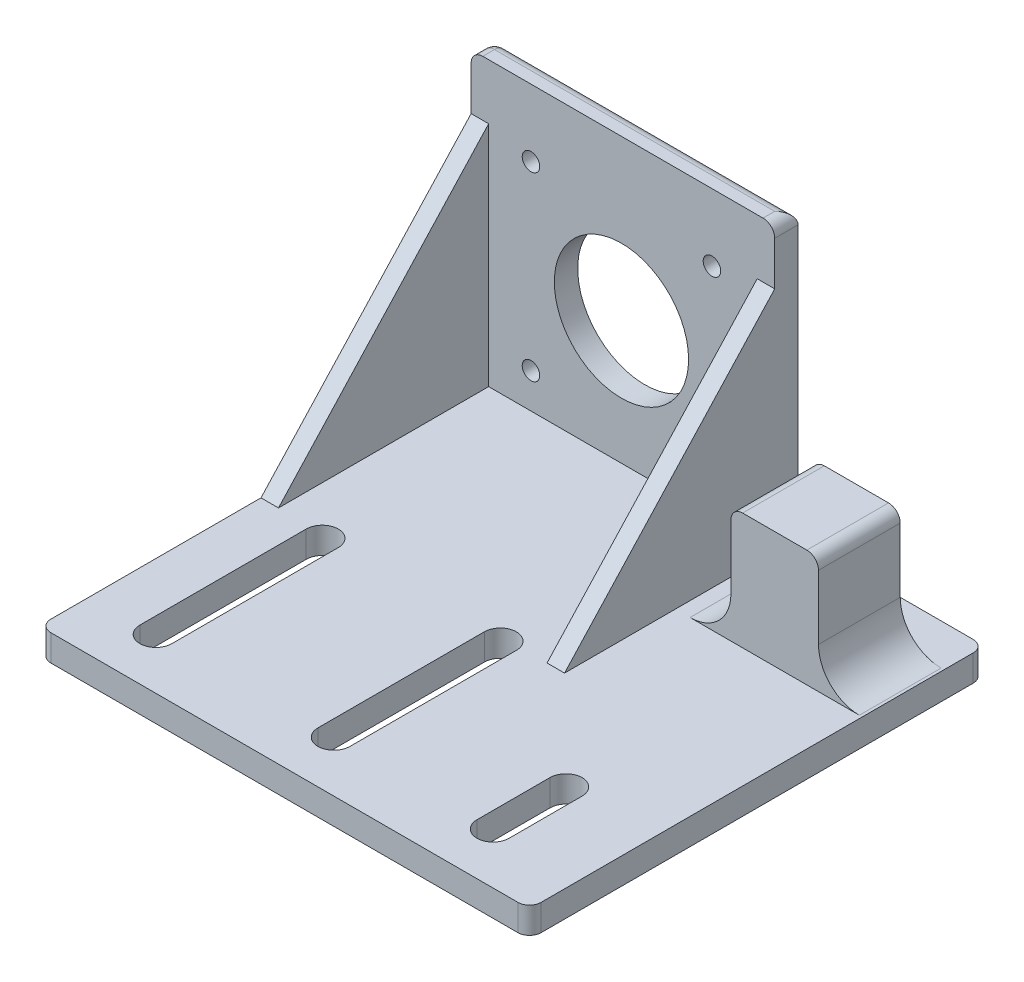
from build123d import *

# Parameters (mm, degrees)
SKETCH1_W               = 84
SKETCH1_H               = 78
BOSS_EXTRUDE1_DEPTH     = 4.5
FILLET2_R               = 2
CUT_EXTRUDE1_DEPTH      = 69.558369292
CUT_EXTRUDE1_DEPTH_BACK = 69.558369292
BOSS_EXTRUDE2_DEPTH     = 48.5
FILLET4_R               = 2
RIB7_REACH              = 115.053
SKETCH4_WALL_W          = 281.181587792
SKETCH4_WALL_H          = 3
RIB8_REACH              = 93.81
SKETCH6_WALL_W          = 238.694589152
SKETCH6_WALL_H          = 3
SKETCH7_R               = 11.5
SKETCH7_R_2             = 1.5
CUT_EXTRUDE2_DEPTH      = 101.244700608
SKETCH8_W               = 15
SKETCH8_H               = 14
BOSS_EXTRUDE3_DEPTH     = 20
FILLET5_R               = 7
FILLET6_R               = 2
SKETCH9_R               = 4
CUT_EXTRUDE3_DEPTH      = 10
CUT_EXTRUDE4_DEPTH      = 84.858511792


with BuildPart() as part:
    # Sketch1 → Boss-Extrude1 (new body)
    with BuildSketch(Plane(origin=(0, 0, 0), x_dir=(1, 0, 0), z_dir=(0, 1, 0))):
        with Locations((0, -15)):
            Rectangle(SKETCH1_W, SKETCH1_H)
    extrude(amount=BOSS_EXTRUDE1_DEPTH)

    # Fillet2
    fillet2_edges = [part.edges().sort_by_distance(p)[0] for p in [
        (-42, 2.25, -24),
        (42, 2.25, -24),
        (42, 2.25, 54),
        (-42, 2.25, 54),
    ]]
    fillet(fillet2_edges, radius=FILLET2_R)

    # Sketch2 → Cut-Extrude1 (cut, two sides)
    with BuildSketch(Plane(origin=(0, 4.5, 0), x_dir=(1, 0, 0), z_dir=(0, 1, 0))) as cut_extrude1_sk:
        with BuildLine():
            Line((-33.5, -16.749999598), (-33.5, -45.249999598))
            ThreePointArc((-33.5, -45.249999598), (-30.750000201, -48), (-28, -45.25))
            Line((-28, -45.25), (-28, -16.749999598))
            ThreePointArc((-28, -16.749999598), (-30.75, -13.999999598), (-33.5, -16.749999598))
        make_face()
        with BuildLine():
            Line((2.5, -16.749999598), (2.5, -45.249999598))
            ThreePointArc((2.5, -45.249999598), (-0.249999799, -48), (-3, -45.25))
            Line((-3, -45.25), (-3, -16.749999598))
            ThreePointArc((-3, -16.749999598), (-0.25, -13.999999598), (2.5, -16.749999598))
        make_face()
    extrude(amount=CUT_EXTRUDE1_DEPTH, mode=Mode.SUBTRACT)
    extrude(cut_extrude1_sk.sketch, amount=-CUT_EXTRUDE1_DEPTH_BACK, mode=Mode.SUBTRACT)

    # Sketch3 → Boss-Extrude2 (add)
    with BuildSketch(Plane(origin=(0, 4.5, 0), x_dir=(1, 0, 0), z_dir=(0, 1, 0))):
        with BuildLine():
            Line((-42, 20), (10, 20))
            Line((10, 20), (10, 24))
            Line((10, 24), (-40, 24))
            ThreePointArc((-40, 24), (-41.414213562, 23.414213562), (-42, 22))
            Line((-42, 22), (-42, 20))
        make_face()
    extrude(amount=BOSS_EXTRUDE2_DEPTH)

    # Fillet4
    fillet4_edges = [part.edges().sort_by_distance(p)[0] for p in [
        (-42, 53, -21),
        (10, 53, -22),
        (-15, 53, -24),
        (-41.414213562, 53, -23.414213562),
    ]]
    fillet(fillet4_edges, radius=FILLET4_R)

    # Sketch4 wall → Rib7 (add, up to next)
    with BuildSketch(Plane(origin=(-42, 24, -2), x_dir=(0, 0.734803444627, -0.678280102733), z_dir=(0, -0.678280102733, -0.734803444627)), mode=Mode.PRIVATE) as rib7_sk1:
        with Locations((0, 1.5)):
            Rectangle(SKETCH4_WALL_W, SKETCH4_WALL_H)
    rib7_tool1 = extrude(rib7_sk1.sketch, amount=RIB7_REACH, mode=Mode.PRIVATE) - part.part
    add(rib7_tool1.solids().sort_by_distance((-42, 24, -2))[0])

    # Sketch6 wall → Rib8 (add, up to next)
    with BuildSketch(Plane(origin=(10, 24, -2), x_dir=(0, -0.734803444627, 0.678280102733), z_dir=(0, -0.678280102733, -0.734803444627)), mode=Mode.PRIVATE) as rib8_sk1:
        with Locations((0, 1.5)):
            Rectangle(SKETCH6_WALL_W, SKETCH6_WALL_H)
    rib8_tool1 = extrude(rib8_sk1.sketch, amount=RIB8_REACH, mode=Mode.PRIVATE) - part.part
    add(rib8_tool1.solids().sort_by_distance((10, 24, -2))[0])

    # Sketch7 → Cut-Extrude2 (cut, through all)
    with BuildSketch(Plane.XY.offset(-20)):
        with Locations((-16.25, 25.65)):
            Circle(SKETCH7_R)
        with Locations((-31.75, 41.5)):
            Circle(SKETCH7_R_2)
        with Locations((-31.75, 10.5)):
            Circle(SKETCH7_R_2)
        with Locations(Location((-0.75, 10.5, 0), (0, 0, 180))):
            Circle(SKETCH7_R_2)
        with Locations(Location((-0.75, 41.5, 0), (0, 0, 180))):
            Circle(SKETCH7_R_2)
    extrude(amount=-CUT_EXTRUDE2_DEPTH, mode=Mode.SUBTRACT)

    # Sketch8 → Boss-Extrude3 (add)
    with BuildSketch(Plane(origin=(0, 4.5, 0), x_dir=(1, 0, 0), z_dir=(0, 1, 0))):
        with Locations((27, 10)):
            Rectangle(SKETCH8_W, SKETCH8_H)
    extrude(amount=BOSS_EXTRUDE3_DEPTH)

    # Fillet5
    fillet5_edges = [part.edges().sort_by_distance(p)[0] for p in [
        (19.5, 4.5, -10),
        (34.5, 4.5, -10),
    ]]
    fillet(fillet5_edges, radius=FILLET5_R)

    # Fillet6
    fillet6_edges = [part.edges().sort_by_distance(p)[0] for p in [
        (19.5, 24.5, -10),
        (34.5, 24.5, -10),
    ]]
    fillet(fillet6_edges, radius=FILLET6_R)

    # Sketch9 → Cut-Extrude3 (cut)
    with BuildSketch(Plane(origin=(0, 0, -17), x_dir=(-1, 0, 0), z_dir=(0, 0, -1))):
        with Locations((-27, 16.5)):
            Circle(SKETCH9_R)
    extrude(amount=-CUT_EXTRUDE3_DEPTH, mode=Mode.SUBTRACT)

    # Sketch10 → Cut-Extrude4 (cut, through all)
    with BuildSketch(Plane(origin=(0, 4.5, 0), x_dir=(1, 0, 0), z_dir=(0, 1, 0))):
        with BuildLine():
            Line((24.25, -32.75), (24.25, -45.25))
            ThreePointArc((24.25, -45.25), (26.999999703, -48), (29.75, -45.250000593))
            Line((29.75, -45.250000593), (29.75, -32.749975496))
            ThreePointArc((29.75, -32.749975496), (26.999987748, -29.999987748), (24.25, -32.75))
        make_face()
    extrude(amount=-CUT_EXTRUDE4_DEPTH, mode=Mode.SUBTRACT)


solid = part.part
